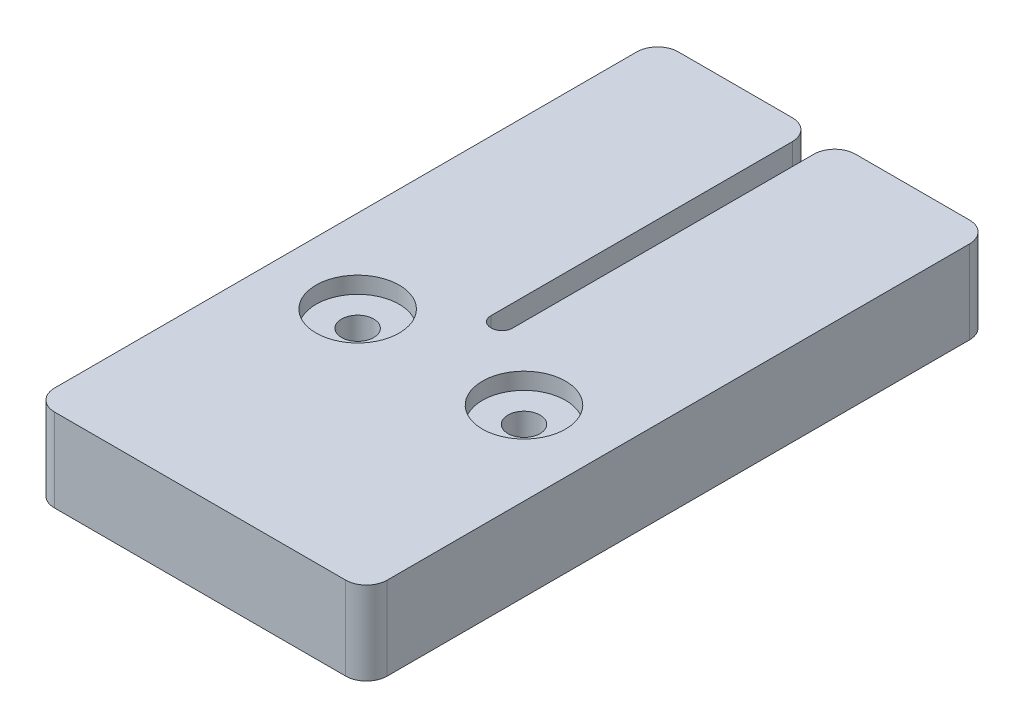
from build123d import *

# Parameters (mm, degrees)
BOSS_EXTRUDE1_DEPTH = 12.7
FILLET1_R           = 3.175
FILLET2_R           = 1.5875
SKETCH2_R           = 2.45745
CUT_EXTRUDE1_DEPTH  = 13.7
SKETCH3_R           = 6.35
CUT_EXTRUDE2_DEPTH  = 2.54


with BuildPart() as part:
    # Sketch1 → Boss-Extrude1 (new body)
    with BuildSketch(Plane(origin=(0, 0, 0), x_dir=(1, 0, 0), z_dir=(0, 1, 0))):
        Polygon((-25.4, 0), (25.4, 0), (25.4, 95.25), (1.651, 95.25), (1.651, 44.45), (-1.651, 44.45), (-1.651, 95.25), (-25.4, 95.25), align=None)
    extrude(amount=BOSS_EXTRUDE1_DEPTH)

    # Fillet1
    fillet1_edges = [part.edges().sort_by_distance(p)[0] for p in [
        (-25.4, 6.35, -95.25),
        (-1.651, 6.35, -95.25),
        (1.651, 6.35, -95.25),
        (25.4, 6.35, -95.25),
        (25.4, 6.35, 0),
        (-25.4, 6.35, 0),
    ]]
    fillet(fillet1_edges, radius=FILLET1_R)

    # Fillet2
    fillet2_edges = [part.edges().sort_by_distance(p)[0] for p in [
        (-1.651, 6.35, -44.45),
        (1.651, 6.35, -44.45),
    ]]
    fillet(fillet2_edges, radius=FILLET2_R)

    # Sketch2 → Cut-Extrude1 (cut, through all)
    with BuildSketch(Plane.XZ):
        with Locations((-12.7, -36.7538)):
            Circle(SKETCH2_R)
        with Locations((12.7, -36.7538)):
            Circle(SKETCH2_R)
    extrude(amount=-CUT_EXTRUDE1_DEPTH, mode=Mode.SUBTRACT)

    # Sketch3 → Cut-Extrude2 (cut)
    with BuildSketch(Plane(origin=(0, 12.7, 0), x_dir=(1, 0, 0), z_dir=(0, 1, 0))):
        with Locations((12.7, 36.7538)):
            Circle(SKETCH3_R)
        with Locations((-12.7, 36.7538)):
            Circle(SKETCH3_R)
    extrude(amount=-CUT_EXTRUDE2_DEPTH, mode=Mode.SUBTRACT)


solid = part.part
